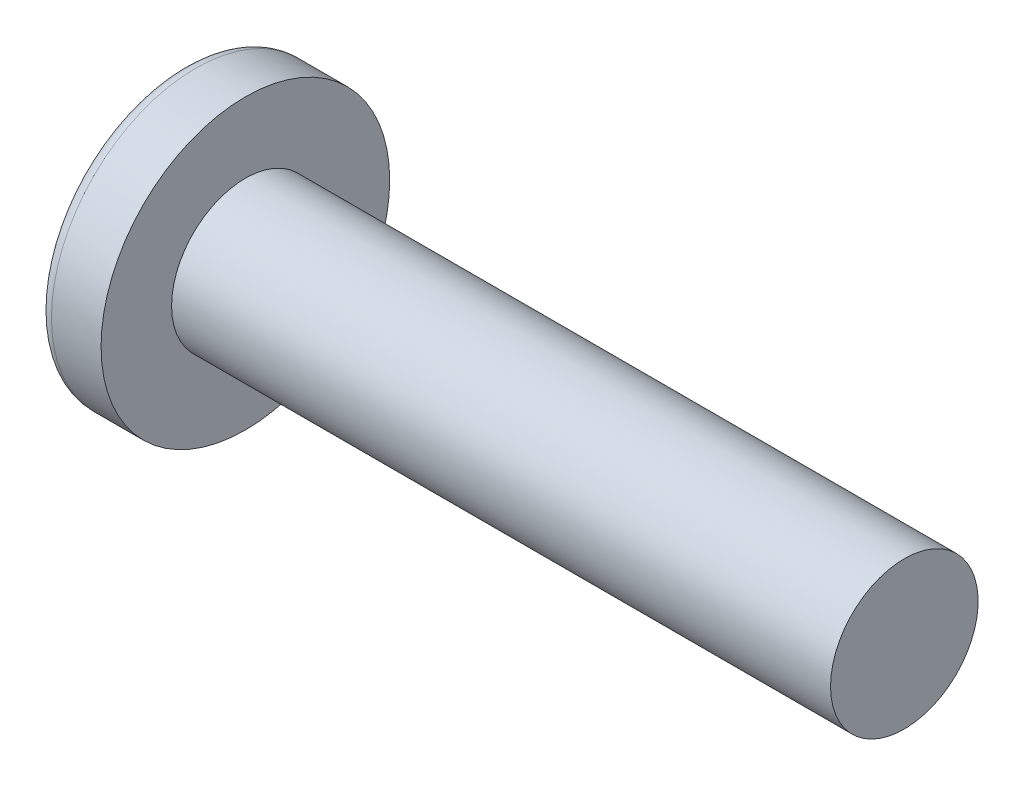
from build123d import *

# Parameters (mm, degrees)
SKETCH3_W         = 0.8128
SKETCH3_H         = 3.6322
SKETCH4_W         = 0.4064
SKETCH4_H         = 0.4064
CIRPATTERN1_COUNT = 2
CIRPATTERN1_ANGLE = 90


with BuildPart() as part:
    # BodySke → Base-Revolve (revolve)
    with BuildSketch(Plane.XY):
        with BuildLine():
            Line((2.032, 1.4224), (2.032, 2.7813))
            Line((2.032, 2.7813), (1.075646615, 2.7813))
            ThreePointArc((1.075646615, 2.7813), (0.960371669, 2.753635341), (0.87020729, 2.676667612))
            ThreePointArc((0.87020729, 2.676667612), (0.223015279, 1.407285528), (0, 0))
            Line((0, 0), (14.732, 0))
            Line((14.732, 0), (14.732, 1.4224))
            Line((14.732, 1.4224), (2.032, 1.4224))
        make_face()
    revolve(axis=Axis((-25.4, 0, 0), (1, 0, 0)))

    # Sketch3 → Cut-Loft1 section 0
    with BuildSketch(Plane(origin=(0, 0, 0), x_dir=(0, 0, -1), z_dir=(1, 0, 0))):
        Rectangle(SKETCH3_W, SKETCH3_H)
    # Sketch4 → Cut-Loft1 section 1
    with BuildSketch(Plane(origin=(2.0066, 0, 0), x_dir=(0, 0, -1), z_dir=(1, 0, 0))):
        Rectangle(SKETCH4_W, SKETCH4_H)
    cut_loft1 = loft(mode=Mode.SUBTRACT)

    # CirPattern1: Cut-Loft1 ×2 about axis
    cirpattern1_axis = Axis((0, 0, 0), (1, 0, 0))
    for i in range(1, CIRPATTERN1_COUNT):
        add(cut_loft1.rotate(cirpattern1_axis, i * CIRPATTERN1_ANGLE / (CIRPATTERN1_COUNT - 1)), mode=Mode.SUBTRACT)


solid = part.part
